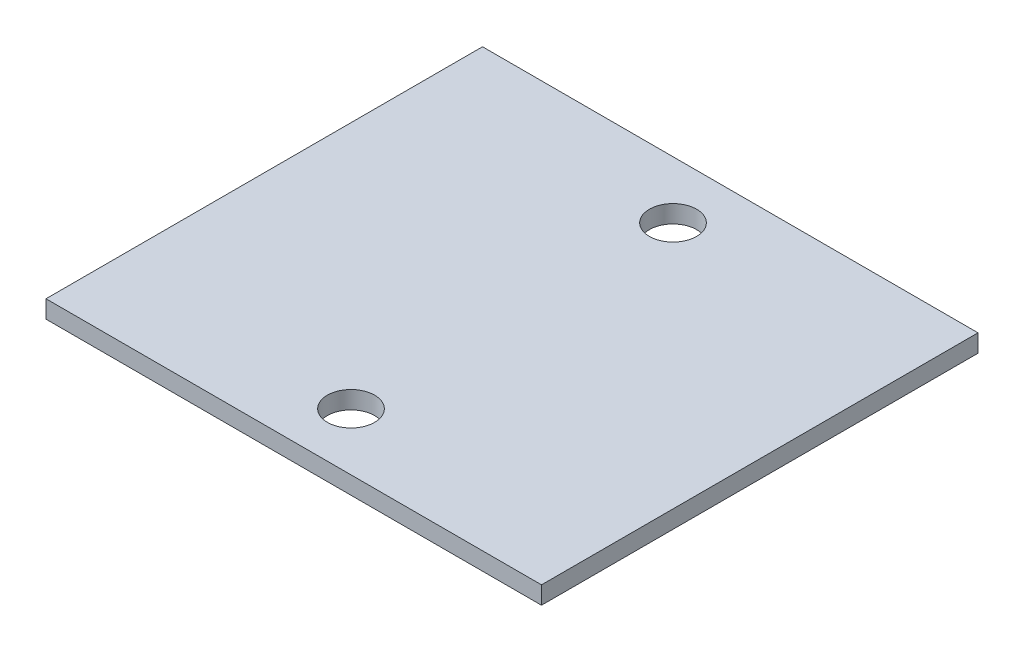
from build123d import *

# Parameters (mm, degrees)
SKETCH_1_W      = 42
SKETCH_1_H      = 37
SKETCH_1_R      = 2
EXTRUDE_1_DEPTH = 1.5


with BuildPart() as part:
    # Эскиз1 → Бобышка-Вытянуть1 (new body)
    with BuildSketch(Plane(origin=(0, 0, 0), x_dir=(1, 0, 0), z_dir=(0, 1, 0))):
        with Locations((21, 18.5)):
            Rectangle(SKETCH_1_W, SKETCH_1_H)
        with Locations((21, 32.148846945)):
            Circle(SKETCH_1_R, mode=Mode.SUBTRACT)
        with Locations((21, 4.851153055)):
            Circle(SKETCH_1_R, mode=Mode.SUBTRACT)
    extrude(amount=EXTRUDE_1_DEPTH)


solid = part.part
